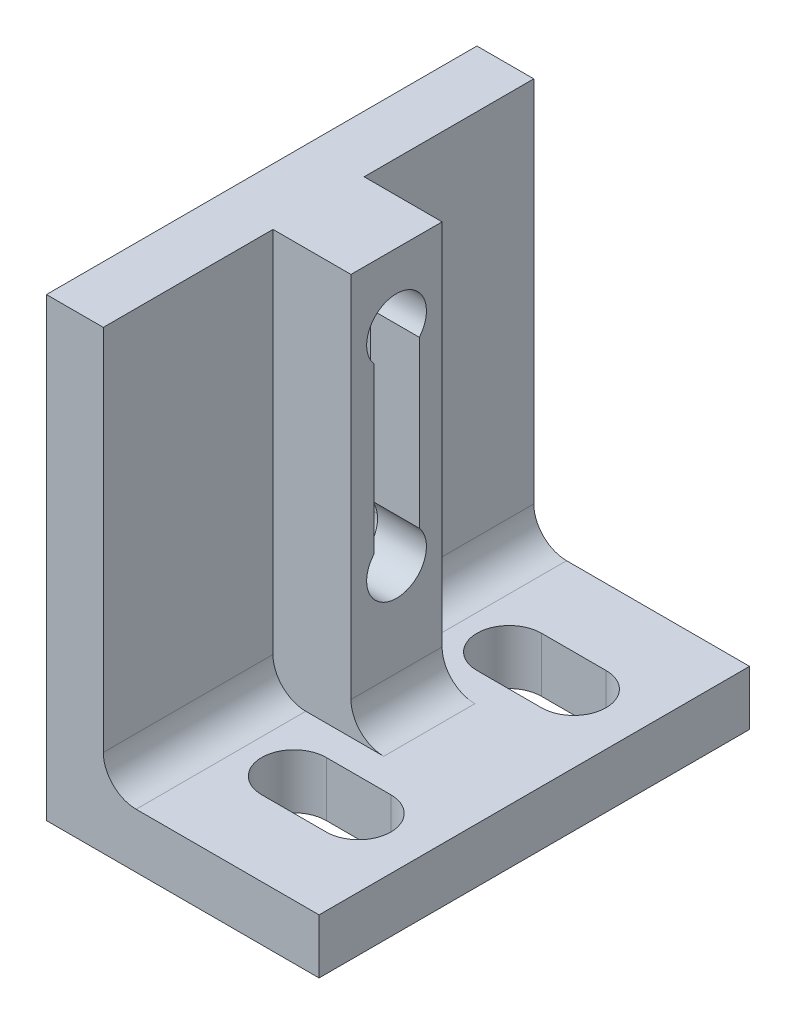
from build123d import *

# Parameters (mm, degrees)
EXTRUDE_THIN1_DEPTH     = 30
EXTRUDE5_DEPTH          = 4.81
SKETCH10_W              = 5.588
SKETCH10_H              = 27.94
BOSS_EXTRUDE1_DEPTH     = 30
CUT_EXTRUDE1_DEPTH      = 16.19
CUT_EXTRUDE1_DEPTH_BACK = 4.81
F_8_32_TAPPED_HOLE1_D   = 4.1656
SKETCH14_W              = 5.4356
SKETCH14_H              = 11.825
CUT_EXTRUDE2_DEPTH      = 27.94
FILLET1_R               = 2.286
FILLET2_R               = 2.286
CUT_EXTRUDE3_DEPTH      = 5.9944


with BuildPart() as part:
    # Sketch1 → Extrude-Thin1 (new body)
    with BuildSketch(Plane.XY):
        Polygon((0, 31.75), (0, 0), (19, 0), (19, 3.81), (3.81, 3.81), (3.81, 31.75), align=None)
    extrude(amount=-EXTRUDE_THIN1_DEPTH)

    # Sketch6 → Extrude5 (cut, through all)
    with BuildSketch(Plane(origin=(0, 3.81, 0), x_dir=(1, 0, 0), z_dir=(0, 1, 0))):
        with BuildLine():
            Line((14.2502, 24.75), (9.7502, 24.75))
            ThreePointArc((9.7502, 24.75), (7.5002, 22.5), (9.7502, 20.25))
            Line((9.7502, 20.25), (14.2502, 20.25))
            ThreePointArc((14.2502, 20.25), (16.5002, 22.5), (14.2502, 24.75))
        make_face()
        with BuildLine():
            Line((9.7502, 9.75), (14.2502, 9.75))
            ThreePointArc((14.2502, 9.75), (16.5002, 7.5), (14.2502, 5.25))
            Line((14.2502, 5.25), (9.7502, 5.25))
            ThreePointArc((9.7502, 5.25), (7.5002, 7.5), (9.7502, 9.75))
        make_face()
    extrude(amount=-EXTRUDE5_DEPTH, mode=Mode.SUBTRACT)

    # Sketch10 → Boss-Extrude1 (add)
    with BuildSketch(Plane.XY):
        with Locations((6.604, 17.78)):
            Rectangle(SKETCH10_W, SKETCH10_H)
    extrude(amount=-BOSS_EXTRUDE1_DEPTH)

    # Sketch4 → Cut-Extrude1 (cut, two sides)
    with BuildSketch(Plane(origin=(3.81, 0, 0), x_dir=(0, 0, -1), z_dir=(1, 0, 0))) as cut_extrude1_sk:
        with BuildLine():
            Line((13.4125, 12.7), (13.4125, 26.924))
            ThreePointArc((13.4125, 26.924), (15, 28.5115), (16.5875, 26.924))
            Line((16.5875, 26.924), (16.5875, 12.7))
            ThreePointArc((16.5875, 12.7), (15, 11.1125), (13.4125, 12.7))
        make_face()
    extrude(amount=CUT_EXTRUDE1_DEPTH, mode=Mode.SUBTRACT)
    extrude(cut_extrude1_sk.sketch, amount=-CUT_EXTRUDE1_DEPTH_BACK, mode=Mode.SUBTRACT)

    # #8-32 Tapped Hole1 (through all)
    with Locations(Plane(origin=(9.398, 0, 0), x_dir=(0, 0, -1), z_dir=(1, 0, 0))):
        with Locations((15, 12.7), (15, 26.924)):
            Hole(F_8_32_TAPPED_HOLE1_D / 2)

    # Sketch14 → Cut-Extrude2 (cut)
    with BuildSketch(Plane(origin=(0, 31.75, 0), x_dir=(1, 0, 0), z_dir=(0, 1, 0))):
        with Locations((6.6802, 24.0875)):
            Rectangle(SKETCH14_W, SKETCH14_H)
        with Locations((6.6802, 5.9125)):
            Rectangle(SKETCH14_W, SKETCH14_H)
    extrude(amount=-CUT_EXTRUDE2_DEPTH, mode=Mode.SUBTRACT)

    # Fillet1
    fillet1_edges = [part.edges().sort_by_distance(p)[0] for p in [
        (9.398, 3.81, -15),
    ]]
    fillet(fillet1_edges, radius=FILLET1_R)

    # Fillet2
    fillet2_edges = [part.edges().sort_by_distance(p)[0] for p in [
        (3.9624, 3.81, -24.0875),
        (3.9624, 3.81, -5.9125),
    ]]
    fillet(fillet2_edges, radius=FILLET2_R)

    # Sketch11 → Cut-Extrude3 (cut)
    with BuildSketch(Plane(origin=(0, 0, 5.175), x_dir=(0, 0, -1), z_dir=(1, 0, 0))):
        with BuildLine():
            Line((17.8001, 12.7), (17.8001, 26.924))
            ThreePointArc((17.8001, 26.924), (20.175, 29.2989), (22.5499, 26.924))
            Line((22.5499, 26.924), (22.5499, 12.7))
            ThreePointArc((22.5499, 12.7), (20.175, 10.3251), (17.8001, 12.7))
        make_face()
    extrude(amount=CUT_EXTRUDE3_DEPTH, mode=Mode.SUBTRACT)


solid = part.part
